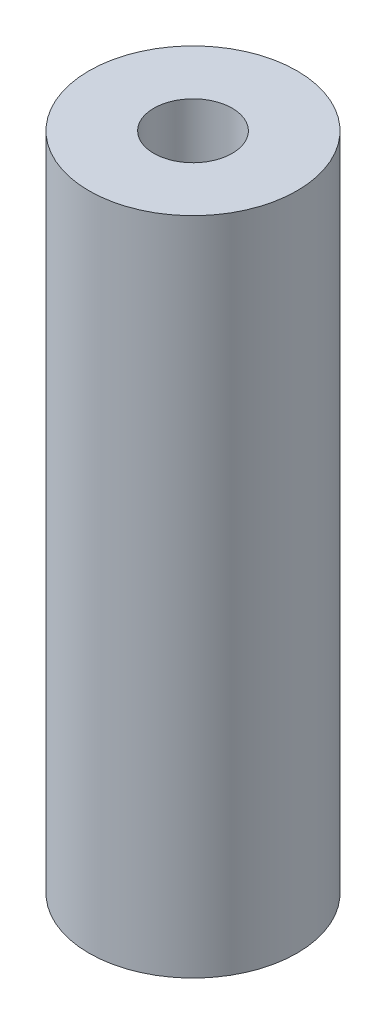
from build123d import *

# Parameters (mm, degrees)
SKETCH1_R             = 3
BOSS_EXTRUDE1_DEPTH   = 19.05
F_4_40_TAPPED_HOLE1_D = 2.2606


with BuildPart() as part:
    # Sketch1 → Boss-Extrude1 (new body)
    with BuildSketch(Plane(origin=(0, 0, 0), x_dir=(1, 0, 0), z_dir=(0, 1, 0))):
        Circle(SKETCH1_R)
    extrude(amount=BOSS_EXTRUDE1_DEPTH)

    # #4-40 Tapped Hole1 (through all)
    with Locations(Plane(origin=(0, 0, 0), x_dir=(-1, 0, 0), z_dir=(0, -1, 0))):
        with Locations((0, 0)):
            Hole(F_4_40_TAPPED_HOLE1_D / 2)


solid = part.part
